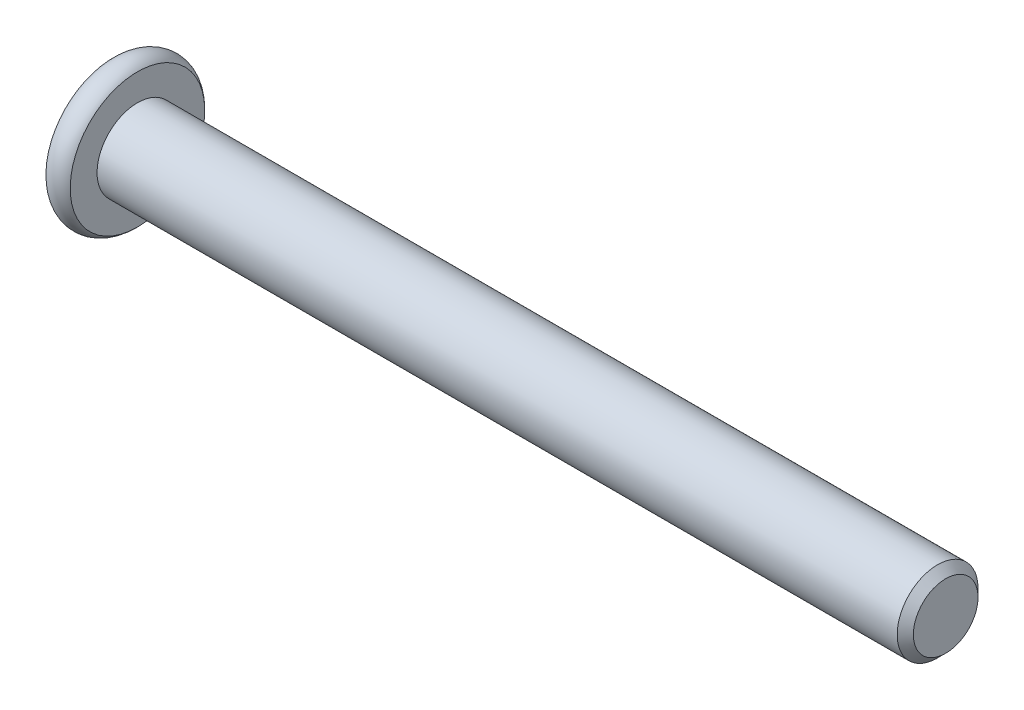
from build123d import *

# Parameters (mm, degrees)
SKETCH2_R           = 2.5
BOSS_EXTRUDE1_DEPTH = 50
CHAMFER1_SIZE       = 0.5
CUT_EXTRUDE1_DEPTH  = 2.3
SKETCH8_R           = 1.782050808
CUT_EXTRUDE2_DEPTH  = 1
CUT_EXTRUDE2_TAPER  = 45


with BuildPart() as part:
    # Sketch2 → Boss-Extrude1 (new body)
    with BuildSketch(Plane(origin=(0, 0, 0), x_dir=(0, 0, -1), z_dir=(1, 0, 0))):
        Circle(SKETCH2_R)
    extrude(amount=-BOSS_EXTRUDE1_DEPTH)

    # Chamfer1
    chamfer1_edges = [part.edges().sort_by_distance(p)[0] for p in [
        (0, 0, 2.5),
    ]]
    chamfer(chamfer1_edges, length=CHAMFER1_SIZE)

    # Sketch6 → Revolve1 (revolve)
    with BuildSketch(Plane.XY):
        with BuildLine():
            Line((-51.5, 0), (-51.5, 4.161437828))
            ThreePointArc((-51.5, 4.161437828), (-50.75, 4.5), (-50, 4.161437828))
            Line((-50, 4.161437828), (-50, 0))
            Line((-50, 0), (-51.5, 0))
        make_face()
    revolve(axis=Axis((-50, 0, 0), (1, 0, 0)))

    # Sketch7 → Cut-Extrude1 (cut)
    with BuildSketch(Plane.ZY.offset(51.5)):
        Polygon((0, 1.732050808), (-1.5, 0.866025404), (-1.5, -0.866025404), (0, -1.732050808), (1.5, -0.866025404), (1.5, 0.866025404), align=None)
    extrude(amount=-CUT_EXTRUDE1_DEPTH, mode=Mode.SUBTRACT)

    # Sketch8 → Cut-Extrude2 (cut)
    with BuildSketch(Plane.ZY.offset(51.5)):
        Circle(SKETCH8_R)
    extrude(amount=-CUT_EXTRUDE2_DEPTH, taper=CUT_EXTRUDE2_TAPER, mode=Mode.SUBTRACT)


solid = part.part
